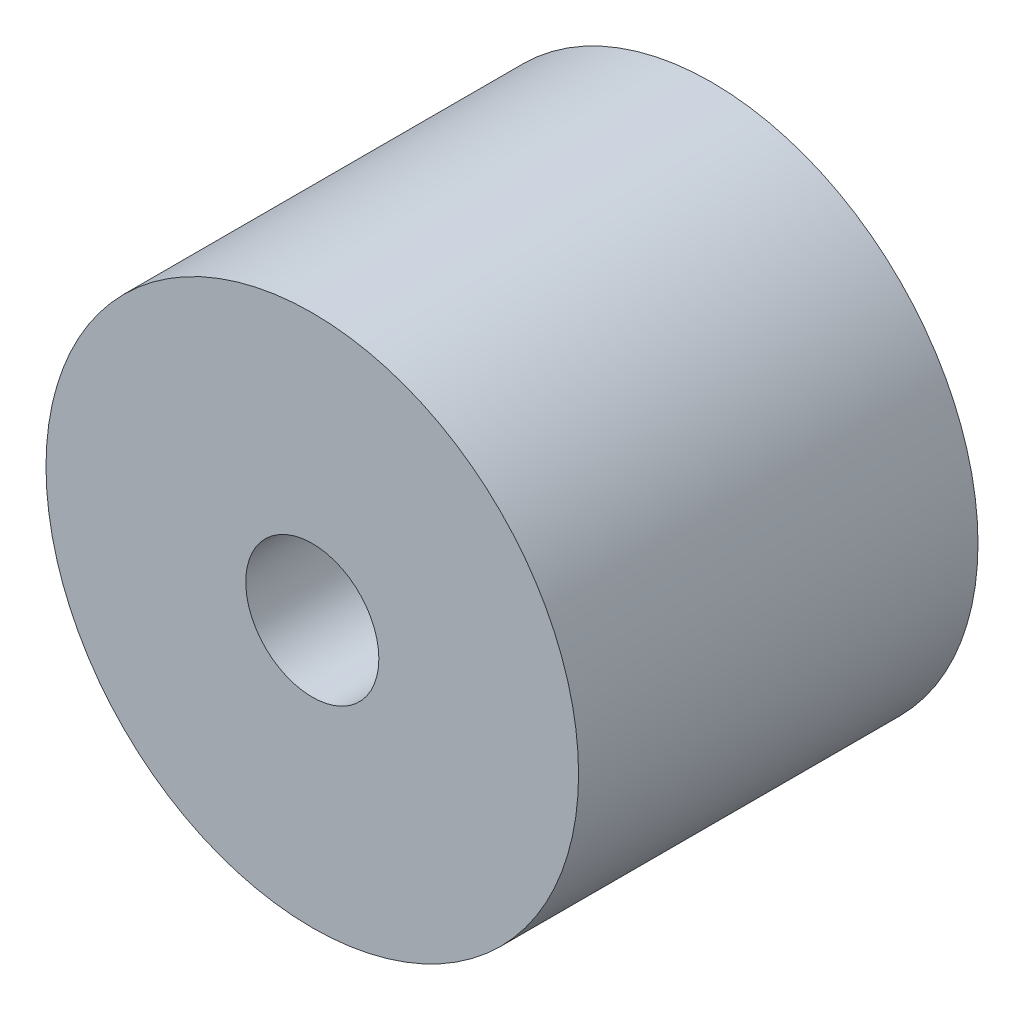
from build123d import *

# Parameters (mm, degrees)
SKETCH1_R           = 3.175
SKETCH1_R_2         = 0.79375
BOSS_EXTRUDE1_DEPTH = 4.7625


with BuildPart() as part:
    # Sketch1 → Boss-Extrude1 (new body)
    with BuildSketch(Plane.XY):
        Circle(SKETCH1_R)
        Circle(SKETCH1_R_2, mode=Mode.SUBTRACT)
    extrude(amount=BOSS_EXTRUDE1_DEPTH)


solid = part.part
